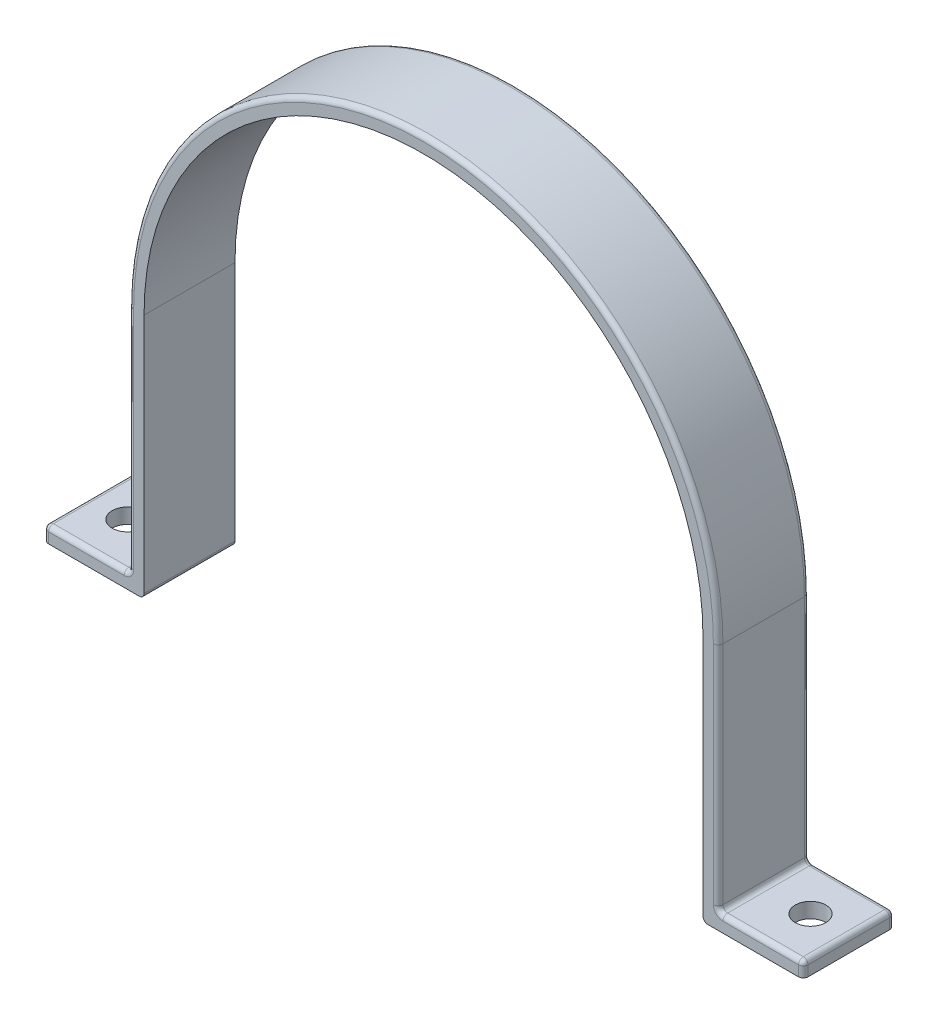
from build123d import *

# Parameters (mm, degrees)
BOSS_EXTRUDE1_DEPTH = 19.05
CUT_EXTRUDE1_REACH  = 5.175
SKETCH2_R           = 3.2
FILLET1_R           = 1


with BuildPart() as part:
    # Sketch1 → Boss-Extrude1 (new body)
    with BuildSketch(Plane.XY):
        with BuildLine():
            Line((21, 51.5), (21, 0))
            Line((21, 0), (0, 0))
            Line((0, 0), (0, 3.175))
            Line((0, 3.175), (17.825, 3.175))
            Line((17.825, 3.175), (17.825, 51.5))
            ThreePointArc((17.825, 51.5), (79.545, 113.22), (141.265, 51.5))
            Line((141.265, 51.5), (141.265, 3.175))
            Line((141.265, 3.175), (159.09, 3.175))
            Line((159.09, 3.175), (159.09, 0))
            Line((159.09, 0), (138.09, 0))
            Line((138.09, 0), (138.09, 51.5))
            ThreePointArc((138.09, 51.5), (79.545, 110.045), (21, 51.5))
        make_face()
    extrude(amount=-BOSS_EXTRUDE1_DEPTH)

    # Sketch2 → Cut-Extrude1 (cut, up to next)
    with BuildSketch(Plane(origin=(0, 3.175, 0), x_dir=(1, 0, 0), z_dir=(0, 1, 0)), mode=Mode.PRIVATE) as cut_extrude1_sk1:
        with Locations((151.09, 9.525)):
            Circle(SKETCH2_R)
    cut_extrude1_tool1 = extrude(cut_extrude1_sk1.sketch, amount=-CUT_EXTRUDE1_REACH, mode=Mode.PRIVATE) & part.part
    add(cut_extrude1_tool1.solids().sort_by_distance((151.09, 3.175, -9.525))[0], mode=Mode.SUBTRACT)
    # Sketch2 → Cut-Extrude1 (cut, up to next)
    with BuildSketch(Plane(origin=(0, 3.175, 0), x_dir=(1, 0, 0), z_dir=(0, 1, 0)), mode=Mode.PRIVATE) as cut_extrude1_sk2:
        with Locations((8, 9.525)):
            Circle(SKETCH2_R)
    cut_extrude1_tool2 = extrude(cut_extrude1_sk2.sketch, amount=-CUT_EXTRUDE1_REACH, mode=Mode.PRIVATE) & part.part
    add(cut_extrude1_tool2.solids().sort_by_distance((8, 3.175, -9.525))[0], mode=Mode.SUBTRACT)

    # Fillet1
    fillet1_edges = [part.edges().sort_by_distance(p)[0] for p in [
        (0, 1.5875, 0),
        (8.9125, 3.175, 0),
        (17.825, 27.3375, 0),
        (79.545, 113.22, 0),
        (141.265, 27.3375, 0),
        (150.1775, 3.175, 0),
        (159.09, 1.5875, 0),
        (159.09, 1.5875, -19.05),
        (21, 0, -9.525),
        (150.1775, 3.175, -19.05),
        (0, 3.175, -9.525),
        (17.825, 3.175, -9.525),
        (141.265, 3.175, -9.525),
        (159.09, 3.175, -9.525),
        (138.09, 0, -9.525),
        (141.265, 27.3375, -19.05),
        (79.545, 113.22, -19.05),
        (17.825, 27.3375, -19.05),
        (8.9125, 3.175, -19.05),
        (0, 1.5875, -19.05),
    ]]
    fillet(fillet1_edges, radius=FILLET1_R)


solid = part.part
